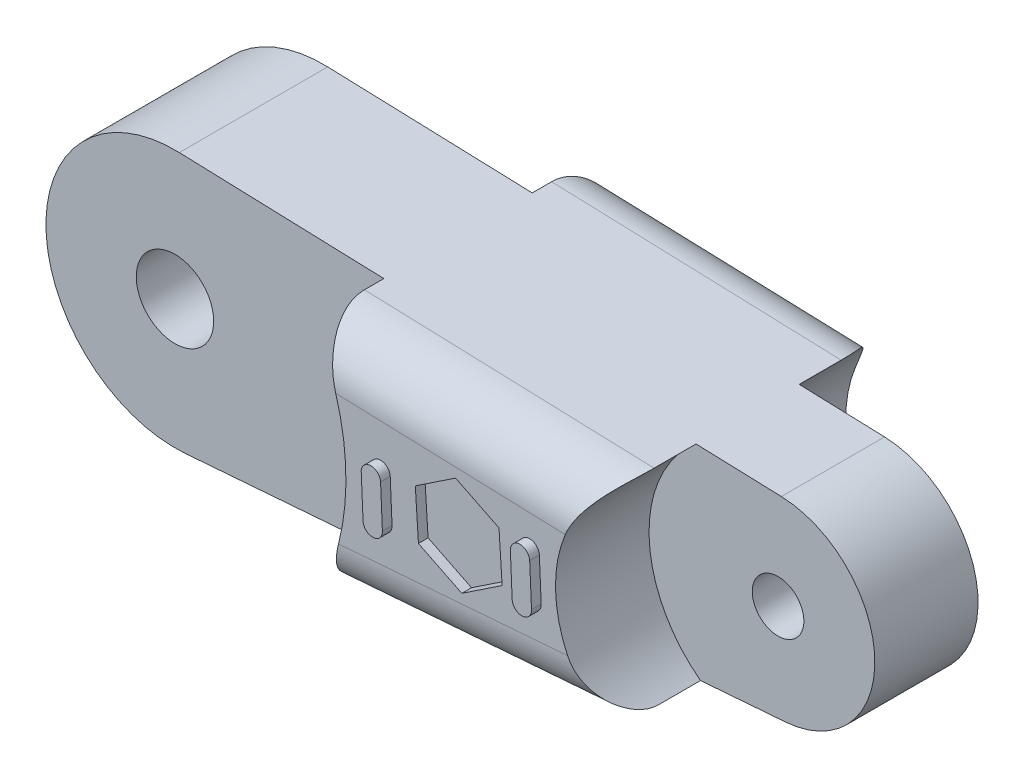
from build123d import *

# Parameters (mm, degrees)
BOSS_EXTRUDE1_DEPTH    = 22.5
SKETCH2_R              = 37.5
SKETCH2_R_2            = 20
CUT_EXTRUDE1_DEPTH     = 11
FILLET1_R              = 8
SKETCH4_R              = 6
SKETCH4_R_2            = 4
CUT_EXTRUDE2_DEPTH     = 40
CUT_EXTRUDE3_DEPTH     = 1.5
BOSS_EXTRUDE2_DEPTH    = 1.5
SKETCH7_R              = 20
CUT_EXTRUDE4_DEPTH     = 3.5
BODY_MOVE_COPY7_ANGLE  = 178.232303169
BODY_MOVE_COPY8_ANGLE  = 1.26
BODY_MOVE_COPY9_ANGLE  = 1.26
BODY_MOVE_COPY10_ANGLE = 180


with BuildPart() as part:
    # Sketch1 → Boss-Extrude1 (new body, symmetric)
    with BuildSketch(Plane(origin=(0, 0, 0), x_dir=(1, 0, 0), z_dir=(0, 1, 0))):
        with BuildLine():
            Line((-91.135271219, -13.013928685), (-1.541618241, -19.940496814))
            ThreePointArc((-1.541618241, -19.940496814), (19.99534612, -0.431431984), (-0.680086883, 19.988433701))
            Line((-0.680086883, 19.988433701), (-90.489122701, 16.932769202))
            ThreePointArc((-90.489122701, 16.932769202), (-104.975567128, 2.265017913), (-91.135271219, -13.013928685))
        make_face()
    extrude(amount=BOSS_EXTRUDE1_DEPTH, both=True)

    # Sketch2 → Cut-Extrude1 (cut)
    with BuildSketch(Plane.XZ.offset(22.5)):
        Circle(SKETCH2_R)
        with Locations((-89.979057538, -1.941443926)):
            Circle(SKETCH2_R_2)
    cut_extrude1 = extrude(amount=-CUT_EXTRUDE1_DEPTH, mode=Mode.SUBTRACT)

    # Mirror1: Cut-Extrude1 across plane
    add(cut_extrude1.mirror(Plane(origin=(0, 0, 0), x_dir=(0, 0, 1), z_dir=(0, -1, 0))), mode=Mode.SUBTRACT)

    # Fillet1
    fillet1_edges = [part.edges().sort_by_distance(p)[0] for p in [
        (-55.557279033, -22.5, 15.764496148),
        (-54.825601141, -22.5, -18.1461856),
        (-54.825601141, 22.5, -18.1461856),
        (-55.557279033, 22.5, 15.764496148),
    ]]
    fillet(fillet1_edges, radius=FILLET1_R)

    # Sketch4 → Cut-Extrude2 (cut)
    with BuildSketch(Plane.XZ.offset(11.5)):
        Circle(SKETCH4_R)
        with Locations((-89.979057538, -1.941443926)):
            Circle(SKETCH4_R_2)
    extrude(amount=-CUT_EXTRUDE2_DEPTH, mode=Mode.SUBTRACT)

    # Sketch5 → Cut-Extrude3 (cut)
    with BuildSketch(Plane(origin=(0, 22.5, 0), x_dir=(1, 0, 0), z_dir=(0, 1, 0))):
        Polygon((-61.556626556, 4.801358237), (-61.398607028, -2.702531632), (-54.82103801, -6.31762764), (-48.401488521, -2.42883378), (-48.559508049, 5.075056088), (-55.137077066, 8.690152097), align=None)
    cut_extrude3 = extrude(amount=-CUT_EXTRUDE3_DEPTH, mode=Mode.SUBTRACT)

    # Sketch6 → Boss-Extrude2 (add)
    with BuildSketch(Plane(origin=(0, 22.5, 0), x_dir=(1, 0, 0), z_dir=(0, 1, 0))):
        with BuildLine():
            Line((-67.627696069, -1.919544043), (-67.627696069, 4.537052574))
            ThreePointArc((-67.627696069, 4.537052574), (-66.127696069, 6.037052574), (-64.627696069, 4.537052574))
            Line((-64.627696069, 4.537052574), (-64.627696069, -1.919544043))
            ThreePointArc((-64.627696069, -1.919544043), (-66.127696069, -3.419544043), (-67.627696069, -1.919544043))
        make_face()
        with BuildLine():
            Line((-44.491273974, -1.919544043), (-44.491273974, 4.537052574))
            ThreePointArc((-44.491273974, 4.537052574), (-42.991273974, 6.037052574), (-41.491273974, 4.537052574))
            Line((-41.491273974, 4.537052574), (-41.491273974, -1.919544043))
            ThreePointArc((-41.491273974, -1.919544043), (-42.991273974, -3.419544043), (-44.491273974, -1.919544043))
        make_face()
    boss_extrude2 = extrude(amount=BOSS_EXTRUDE2_DEPTH)

    # Mirror2: Cut-Extrude3, Boss-Extrude2 across plane
    add(cut_extrude3.mirror(Plane(origin=(0, 0, 0), x_dir=(0, 0, 1), z_dir=(0, -1, 0))), mode=Mode.SUBTRACT)
    add(boss_extrude2.mirror(Plane(origin=(0, 0, 0), x_dir=(0, 0, 1), z_dir=(0, -1, 0))))

    # Sketch7 → Cut-Extrude4 (cut)
    with BuildSketch(Plane.XZ.offset(11.5)):
        with Locations((-89.979057538, -1.941443926)):
            Circle(SKETCH7_R)
    cut_extrude4 = extrude(amount=-CUT_EXTRUDE4_DEPTH, mode=Mode.SUBTRACT)

    # Mirror3: Cut-Extrude4 across plane
    add(cut_extrude4.mirror(Plane.ZX), mode=Mode.SUBTRACT)


with BuildPart() as part_1:
    # Body-Move/Copy1: moved
    add(part.part.moved(Location((89.979057538, 0, 1.941443926))))


with BuildPart() as part_2:
    # Body-Move/Copy7: moved
    add(part_1.part.rotate(Axis((0, 0, 0), (-0.015427289, -0.70702263, 0.70702263)), BODY_MOVE_COPY7_ANGLE))


with BuildPart() as part_3:
    # Body-Move/Copy8: moved
    add(part_2.part.rotate(Axis((0, 0, 0), (0, 0, -1)), BODY_MOVE_COPY8_ANGLE))


with BuildPart() as part_4:
    # Body-Move/Copy9: moved
    add(part_3.part.rotate(Axis((0, 0, 0), (0, 0, 1)), BODY_MOVE_COPY9_ANGLE))


with BuildPart() as part_5:
    # Body-Move/Copy10: moved
    add(part_4.part.rotate(Axis((0, 0, 0), (1, 0, 0)), BODY_MOVE_COPY10_ANGLE))


solid = part_5.part
